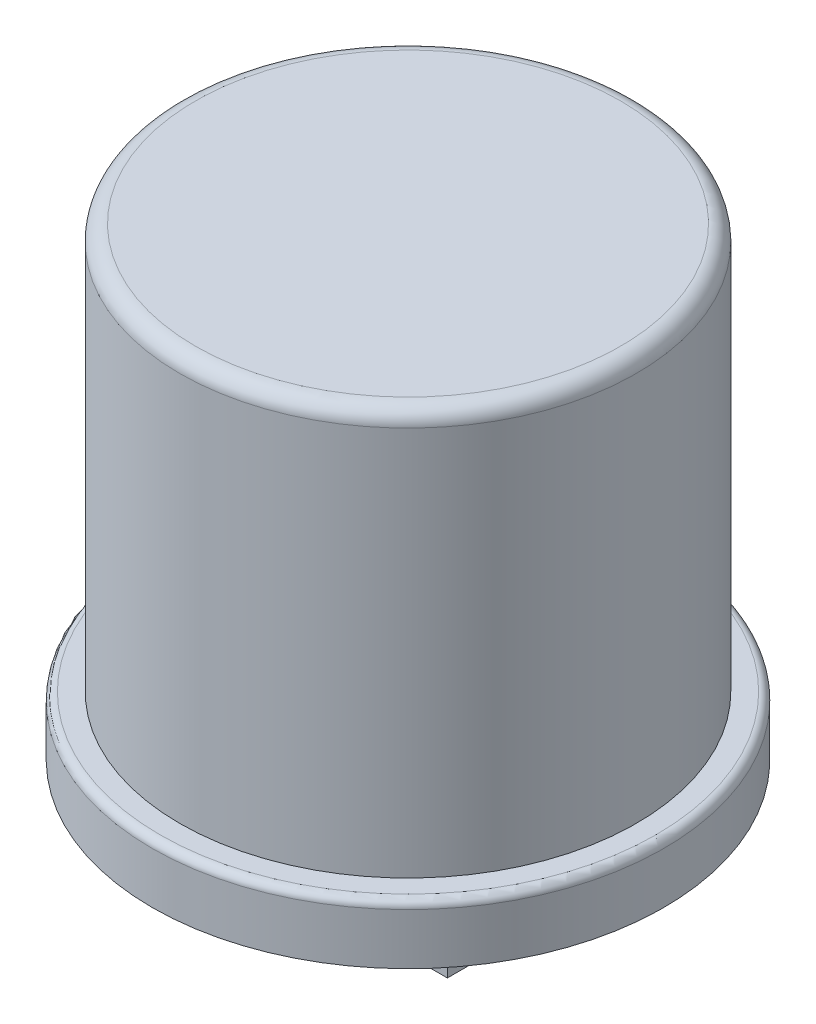
from build123d import *

# Parameters (mm, degrees)
SKETCH1_R           = 6.5
BOSS_EXTRUDE1_DEPTH = 1.5
SKETCH2_R           = 5.8
BOSS_EXTRUDE2_DEPTH = 10.3
FILLET1_R           = 0.4
SKETCH3_R           = 5
CUT_EXTRUDE1_DEPTH  = 4.8
BOSS_EXTRUDE3_DEPTH = 4.8
SKETCH5_W           = 2
SKETCH5_H           = 0.8
SKETCH5_W_2         = 1
SKETCH5_H_2         = 3.8
BOSS_EXTRUDE4_DEPTH = 7.2
CUT_EXTRUDE2_REACH  = 10.4
BOSS_EXTRUDE5_DEPTH = 3.8
FILLET2_R           = 0.1
FILLET3_R           = 0.2


with BuildPart() as part:
    # Sketch1 → Boss-Extrude1 (new body)
    with BuildSketch(Plane(origin=(0, 0, 0), x_dir=(1, 0, 0), z_dir=(0, 1, 0))):
        Circle(SKETCH1_R)
    extrude(amount=BOSS_EXTRUDE1_DEPTH)

    # Sketch2 → Boss-Extrude2 (add)
    with BuildSketch(Plane(origin=(0, 1.5, 0), x_dir=(1, 0, 0), z_dir=(0, 1, 0))):
        Circle(SKETCH2_R)
    extrude(amount=BOSS_EXTRUDE2_DEPTH)

    # Fillet1
    fillet1_edges = [part.edges().sort_by_distance(p)[0] for p in [
        (-5.8, 11.8, 0),
    ]]
    fillet(fillet1_edges, radius=FILLET1_R)

    # Sketch3 → Cut-Extrude1 (cut)
    with BuildSketch(Plane.XZ):
        Circle(SKETCH3_R)
    extrude(amount=-CUT_EXTRUDE1_DEPTH, mode=Mode.SUBTRACT)

    # Sketch4 → Boss-Extrude3 (add)
    with BuildSketch(Plane.XZ.offset(-4.8)):
        with BuildLine():
            Line((-4.990991885, 0.3), (-2.9, 0.3))
            Line((-2.9, 0.3), (-2.9, -0.3))
            Line((-2.9, -0.3), (-4.990991885, -0.3))
            ThreePointArc((-4.990991885, -0.3), (-5, 0), (-4.990991885, 0.3))
        make_face()
        with BuildLine():
            Line((2.9, 0.3), (2.9, -0.3))
            Line((2.9, -0.3), (4.990991885, -0.3))
            ThreePointArc((4.990991885, -0.3), (5, 0), (4.990991885, 0.3))
            Line((4.990991885, 0.3), (2.9, 0.3))
        make_face()
        with BuildLine():
            Line((-0.3, 4.990991885), (-0.3, 2.7))
            Line((-0.3, 2.7), (0.3, 2.7))
            Line((0.3, 2.7), (0.3, 4.990991885))
            ThreePointArc((0.3, 4.990991885), (0, 5), (-0.3, 4.990991885))
        make_face()
        with BuildLine():
            Line((0.3, -2.7), (-0.3, -2.7))
            Line((-0.3, -2.7), (-0.3, -4.990991885))
            ThreePointArc((-0.3, -4.990991885), (0, -5), (0.3, -4.990991885))
            Line((0.3, -4.990991885), (0.3, -2.7))
        make_face()
    extrude(amount=BOSS_EXTRUDE3_DEPTH)

    # Sketch5 → Boss-Extrude4 (add)
    with BuildSketch(Plane.XZ.offset(-4.8)):
        with Locations((0, 2.3)):
            Rectangle(SKETCH5_W, SKETCH5_H)
        with Locations((-2.4, 0)):
            Rectangle(SKETCH5_W_2, SKETCH5_H_2)
        with Locations((2.4, 0)):
            Rectangle(SKETCH5_W_2, SKETCH5_H_2)
        with Locations((0, -2.3)):
            Rectangle(SKETCH5_W, SKETCH5_H)
    extrude(amount=BOSS_EXTRUDE4_DEPTH)

    # Sketch6 → Cut-Extrude2 (cut, up to next)
    with BuildSketch(Plane.XY.offset(1.9), mode=Mode.PRIVATE) as cut_extrude2_sk1:
        Polygon((-1.9, -2.4), (-1.9, -1.9625), (-2.4, -2.4), align=None)
    cut_extrude2_tool1 = extrude(cut_extrude2_sk1.sketch, amount=-CUT_EXTRUDE2_REACH, mode=Mode.PRIVATE) & part.part
    add(cut_extrude2_tool1.solids().sort_by_distance((-2.066667, -2.254167, 1.9))[0], mode=Mode.SUBTRACT)
    # Sketch6 → Cut-Extrude2 (cut, up to next)
    with BuildSketch(Plane.XY.offset(1.9), mode=Mode.PRIVATE) as cut_extrude2_sk2:
        Polygon((1.9, -1.9625), (1.9, -2.4), (2.4, -2.4), align=None)
    cut_extrude2_tool2 = extrude(cut_extrude2_sk2.sketch, amount=-CUT_EXTRUDE2_REACH, mode=Mode.PRIVATE) & part.part
    add(cut_extrude2_tool2.solids().sort_by_distance((2.066667, -2.254167, 1.9))[0], mode=Mode.SUBTRACT)

    # Sketch6_3 → Boss-Extrude5 (add)
    with BuildSketch(Plane.XY.offset(1.9)):
        Polygon((-1.6, -1.7), (-1.9, -1.4), (-1.9, -1.9625), align=None)
        Polygon((1.6, -1.7), (1.9, -1.9625), (1.9, -1.4), align=None)
    extrude(amount=-BOSS_EXTRUDE5_DEPTH)

    # Fillet2
    fillet2_edges = [part.edges().sort_by_distance(p)[0] for p in [
        (-1.6, -1.7, 0),
        (1.6, -1.7, 0),
    ]]
    fillet(fillet2_edges, radius=FILLET2_R)

    # Fillet3
    fillet3_edges = [part.edges().sort_by_distance(p)[0] for p in [
        (-6.5, 1.5, 0),
    ]]
    fillet(fillet3_edges, radius=FILLET3_R)


solid = part.part
